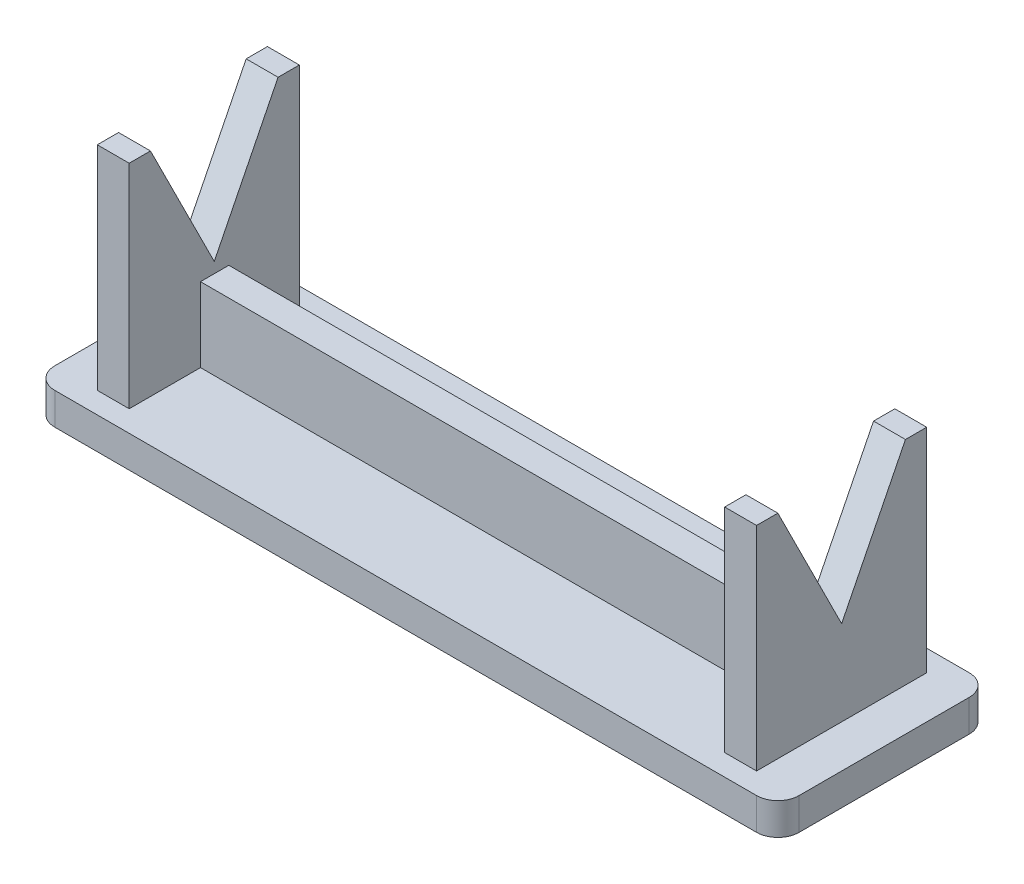
from build123d import *

# Parameters (mm, degrees)
EXTRUDE_451_DEPTH           = 3
SKETCH_505_W                = 3
SKETCH_505_H                = 16
EXTRUDE_763_DEPTH           = 20
CUT_EXTRUDE_1013_DEPTH      = 5
CUT_EXTRUDE_1013_DEPTH_BACK = 3
SKETCH_8_W                  = 3
SKETCH_8_H                  = 16
EXTRUDE_1404_DEPTH          = 20
CUT_EXTRUDE_1670_DEPTH      = 64
CUT_EXTRUDE_1670_DEPTH_BACK = 3
SKETCH_11_W                 = 56
SKETCH_11_H                 = 2.665153407
EXTRUDE_1980_DEPTH          = 7


with BuildPart() as part:
    # Sketch 219 → Extrude 451 (new body)
    with BuildSketch(Plane(origin=(0, 0, 0), x_dir=(1, 0, 0), z_dir=(0, 1, 0))):
        with BuildLine():
            Line((2, 0), (68, 0))
            ThreePointArc((68, 0), (69.414213562, 0.585786438), (70, 2))
            Line((70, 2), (70, 18))
            ThreePointArc((70, 18), (69.414213562, 19.414213562), (68, 20))
            Line((68, 20), (2, 20))
            ThreePointArc((2, 20), (0.585786438, 19.414213562), (0, 18))
            Line((0, 18), (0, 2))
            ThreePointArc((0, 2), (0.585786438, 0.585786438), (2, 0))
        make_face()
    extrude(amount=EXTRUDE_451_DEPTH)

    # Sketch 505 → Extrude 763 (add)
    with BuildSketch(Plane(origin=(0, 3, 0), x_dir=(1, 0, 0), z_dir=(0, 1, 0))):
        with Locations((5.5, 10)):
            Rectangle(SKETCH_505_W, SKETCH_505_H)
    extrude(amount=EXTRUDE_763_DEPTH)

    # Sketch 818 → Cut-Extrude 1013 (cut, two sides)
    with BuildSketch(Plane.ZY.offset(-4)) as cut_extrude_1013_sk:
        Polygon((-45.532064127, 82.064128255), (-16, 23), (-10, 11), (-4, 23), (25.532064127, 82.064128255), (25.532064127, 214.135534064), (-45.532064127, 214.135534064), align=None)
    extrude(amount=CUT_EXTRUDE_1013_DEPTH, mode=Mode.SUBTRACT)
    extrude(cut_extrude_1013_sk.sketch, amount=-CUT_EXTRUDE_1013_DEPTH_BACK, mode=Mode.SUBTRACT)

    # Эскиз8 → Extrude 1404 (add)
    with BuildSketch(Plane(origin=(31.408501121, 3, 2.625790974), x_dir=(1, 0, 0), z_dir=(0, 1, 0))):
        with Locations((33.091498879, 12.625790974)):
            Rectangle(SKETCH_8_W, SKETCH_8_H)
    extrude(amount=EXTRUDE_1404_DEPTH)

    # Эскиз10 → Cut-Extrude 1670 (cut, two sides)
    with BuildSketch(Plane(origin=(63, 0, 2.625790974), x_dir=(0, 0, 1), z_dir=(-1, 0, 0))) as cut_extrude_1670_sk:
        Polygon((-48.157855101, 82.064128255), (-18.625790974, 23), (-12.625790974, 11), (-6.625790974, 23), (22.906273154, 82.064128255), (22.906273154, 214.135534064), (-48.157855101, 214.135534064), align=None)
    extrude(amount=CUT_EXTRUDE_1670_DEPTH, mode=Mode.SUBTRACT)
    extrude(cut_extrude_1670_sk.sketch, amount=-CUT_EXTRUDE_1670_DEPTH_BACK, mode=Mode.SUBTRACT)

    # Эскиз11 → Extrude 1980 (add)
    with BuildSketch(Plane(origin=(0, 3, 0), x_dir=(1, 0, 0), z_dir=(0, 1, 0))):
        with Locations((35, 10.036015586)):
            Rectangle(SKETCH_11_W, SKETCH_11_H)
    extrude(amount=EXTRUDE_1980_DEPTH)


solid = part.part
